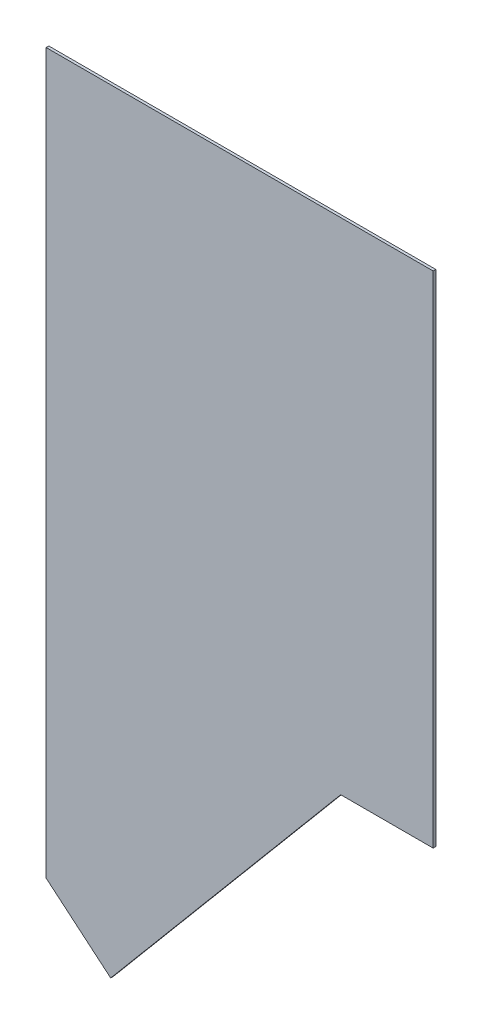
from build123d import *

# Parameters (mm, degrees)
SKETCH1_W           = 304.8
SKETCH1_H           = 609.6
BOSS_EXTRUDE1_DEPTH = 2.1082
CUT_EXTRUDE1_DEPTH  = 2.1082


with BuildPart() as part:
    # Sketch1 → Boss-Extrude1 (new body)
    with BuildSketch(Plane.XY):
        with Locations((101.6, -304.8)):
            Rectangle(SKETCH1_W, SKETCH1_H)
    extrude(amount=BOSS_EXTRUDE1_DEPTH)

    # Sketch2 → Cut-Extrude1 (cut)
    with BuildSketch(Plane.XY.offset(2.1082)):
        Polygon((-50.8, -609.6), (-50.8, -566.618355908), (0, -609.30496414), (156.491241029, -423.069623049), (181.170170025, -393.7), (254, -393.7), (254, -609.6), align=None)
    extrude(amount=-CUT_EXTRUDE1_DEPTH, mode=Mode.SUBTRACT)


solid = part.part
